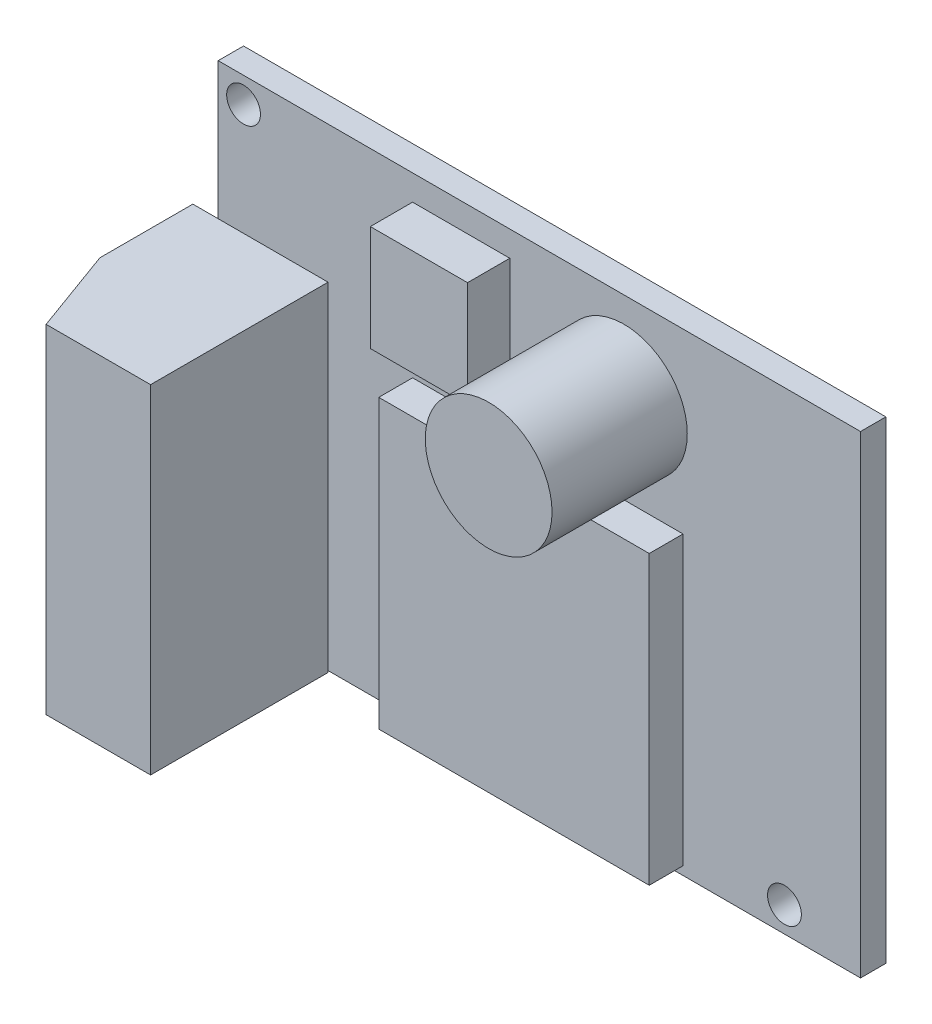
from build123d import *

# Parameters (mm, degrees)
SKETCH1_W           = 38
SKETCH1_H           = 28
BOSS_EXTRUDE1_DEPTH = 1.5
SKETCH2_R           = 3.75
BOSS_EXTRUDE2_DEPTH = 8
SKETCH3_W           = 5.75
SKETCH3_H           = 6.25
BOSS_EXTRUDE3_DEPTH = 2.5
SKETCH4_W           = 16
SKETCH4_H           = 17
BOSS_EXTRUDE4_DEPTH = 2
SKETCH5_R           = 1
CUT_EXTRUDE1_DEPTH  = 2
SKETCH7_R           = 1
CUT_EXTRUDE3_DEPTH  = 2
SKETCH8_W           = 8
SKETCH8_H           = 20
BOSS_EXTRUDE5_DEPTH = 10.5
CHAMFER1_SIZE       = 5
CHAMFER1_SIZE2      = 1.819851171


with BuildPart() as part:
    # Sketch1 → Boss-Extrude1 (new body)
    with BuildSketch(Plane.XY):
        Rectangle(SKETCH1_W, SKETCH1_H)
    extrude(amount=BOSS_EXTRUDE1_DEPTH)

    # Sketch2 → Boss-Extrude2 (add)
    with BuildSketch(Plane.XY.offset(1.5)):
        with Locations((5, 8.75)):
            Circle(SKETCH2_R)
    extrude(amount=BOSS_EXTRUDE2_DEPTH)

    # Sketch3 → Boss-Extrude3 (add)
    with BuildSketch(Plane.XY.offset(1.5)):
        with Locations((-4.625, 9.375)):
            Rectangle(SKETCH3_W, SKETCH3_H)
    extrude(amount=BOSS_EXTRUDE3_DEPTH)

    # Sketch4 → Boss-Extrude4 (add)
    with BuildSketch(Plane.XY.offset(1.5)):
        with Locations((0.5, -5)):
            Rectangle(SKETCH4_W, SKETCH4_H)
    extrude(amount=BOSS_EXTRUDE4_DEPTH)

    # Sketch5 → Cut-Extrude1 (cut)
    with BuildSketch(Plane.XY.offset(1.5)):
        with Locations((14.5, -12.5)):
            Circle(SKETCH5_R)
    extrude(amount=-CUT_EXTRUDE1_DEPTH, mode=Mode.SUBTRACT)

    # Sketch7 → Cut-Extrude3 (cut)
    with BuildSketch(Plane.XY.offset(1.5)):
        with Locations((-17.5, 12.5)):
            Circle(SKETCH7_R)
    extrude(amount=-CUT_EXTRUDE3_DEPTH, mode=Mode.SUBTRACT)

    # Sketch8 → Boss-Extrude5 (add)
    with BuildSketch(Plane.XY.offset(1.5)):
        with Locations((-16.5, -4.1)):
            Rectangle(SKETCH8_W, SKETCH8_H)
    extrude(amount=BOSS_EXTRUDE5_DEPTH)

    # Chamfer1
    chamfer1_edges = [part.edges().sort_by_distance(p)[0] for p in [
        (-20.5, -4.1, 12),
    ]]
    chamfer1_side = [part.faces().sort_by_distance(p)[0] for p in [
        (-20.5, -4.1, 6.75),
    ]]
    chamfer(chamfer1_edges, length=CHAMFER1_SIZE, length2=CHAMFER1_SIZE2, reference=chamfer1_side[0])


solid = part.part
